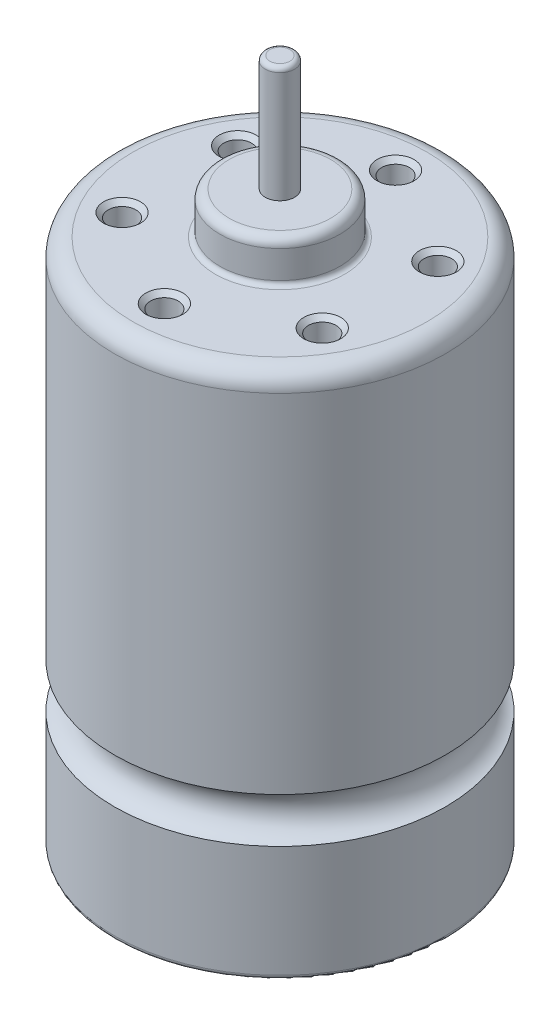
from build123d import *

# Parameters (mm, degrees)
SKETCH1_R           = 17.9
BOSS_EXTRUDE1_DEPTH = 57
SKETCH3_R           = 6.5
BOSS_EXTRUDE3_DEPTH = 4.5
SKETCH4_R           = 1.585
BOSS_EXTRUDE4_DEPTH = 17
SKETCH5_R           = 2.5
SKETCH6_R           = 5.1
BOSS_EXTRUDE5_DEPTH = 3
SKETCH7_R           = 1.585
BOSS_EXTRUDE6_DEPTH = 1
SKETCH8_R           = 1.5
CUT_EXTRUDE1_DEPTH  = 7
CHAMFER1_SIZE       = 0.5
FILLET2_R           = 1
FILLET1_R           = 2
FILLET3_R           = 0.5


with BuildPart() as part:
    # Sketch1 → Boss-Extrude1 (new body)
    with BuildSketch(Plane(origin=(0, 0, 0), x_dir=(1, 0, 0), z_dir=(0, 1, 0))):
        Circle(SKETCH1_R)
    extrude(amount=BOSS_EXTRUDE1_DEPTH)

    # Sketch3 → Boss-Extrude3 (add)
    with BuildSketch(Plane(origin=(0, 57, 0), x_dir=(1, 0, 0), z_dir=(0, 1, 0))):
        Circle(SKETCH3_R)
    extrude(amount=BOSS_EXTRUDE3_DEPTH)

    # Sketch4 → Boss-Extrude4 (add)
    with BuildSketch(Plane(origin=(0, 57, 0), x_dir=(1, 0, 0), z_dir=(0, 1, 0))):
        Circle(SKETCH4_R)
    extrude(amount=BOSS_EXTRUDE4_DEPTH)

    # Sketch5 → Cut-Revolve1 (revolve, cut)
    with BuildSketch(Plane.XY):
        with Locations((-18.5, 15)):
            Circle(SKETCH5_R)
    revolve(axis=Axis((0, 74, 0), (0, -1, 0)), mode=Mode.SUBTRACT)

    # Sketch6 → Boss-Extrude5 (add)
    with BuildSketch(Plane.XZ):
        Circle(SKETCH6_R)
    extrude(amount=BOSS_EXTRUDE5_DEPTH)

    # Sketch7 → Boss-Extrude6 (add)
    with BuildSketch(Plane.XZ.offset(3)):
        Circle(SKETCH7_R)
    extrude(amount=BOSS_EXTRUDE6_DEPTH)

    # Sketch8 → Cut-Extrude1 (cut)
    with BuildSketch(Plane(origin=(0, 57, 0), x_dir=(1, 0, 0), z_dir=(0, 1, 0))):
        with Locations((0, -12.5)):
            Circle(SKETCH8_R)
        with Locations((-10.825317547, -6.25)):
            Circle(SKETCH8_R)
        with Locations((-10.825317547, 6.25)):
            Circle(SKETCH8_R)
        with Locations((0, 12.5)):
            Circle(SKETCH8_R)
        with Locations((10.825317547, 6.25)):
            Circle(SKETCH8_R)
        with Locations((10.825317547, -6.25)):
            Circle(SKETCH8_R)
    extrude(amount=-CUT_EXTRUDE1_DEPTH, mode=Mode.SUBTRACT)

    # Chamfer1
    chamfer1_edges = [part.edges().sort_by_distance(p)[0] for p in [
        (-1.5, 57, 12.5),
        (9.325317547, 57, 6.25),
        (9.325317547, 57, -6.25),
        (-1.5, 57, -12.5),
        (-12.325317547, 57, -6.25),
        (-12.325317547, 57, 6.25),
    ]]
    chamfer(chamfer1_edges, length=CHAMFER1_SIZE)

    # Fillet2
    fillet2_edges = [part.edges().sort_by_distance(p)[0] for p in [
        (-5.1, -3, 0),
        (-6.5, 61.5, 0),
    ]]
    fillet(fillet2_edges, radius=FILLET2_R)

    # Fillet1
    fillet1_edges = [part.edges().sort_by_distance(p)[0] for p in [
        (-17.9, 57, 0),
    ]]
    fillet(fillet1_edges, radius=FILLET1_R)

    # Fillet3
    fillet3_edges = [part.edges().sort_by_distance(p)[0] for p in [
        (-1.585, 74, 0),
        (-17.9, 0, 0),
        (-5.1, 0, 0),
        (-6.5, 57, 0),
    ]]
    fillet(fillet3_edges, radius=FILLET3_R)


solid = part.part
